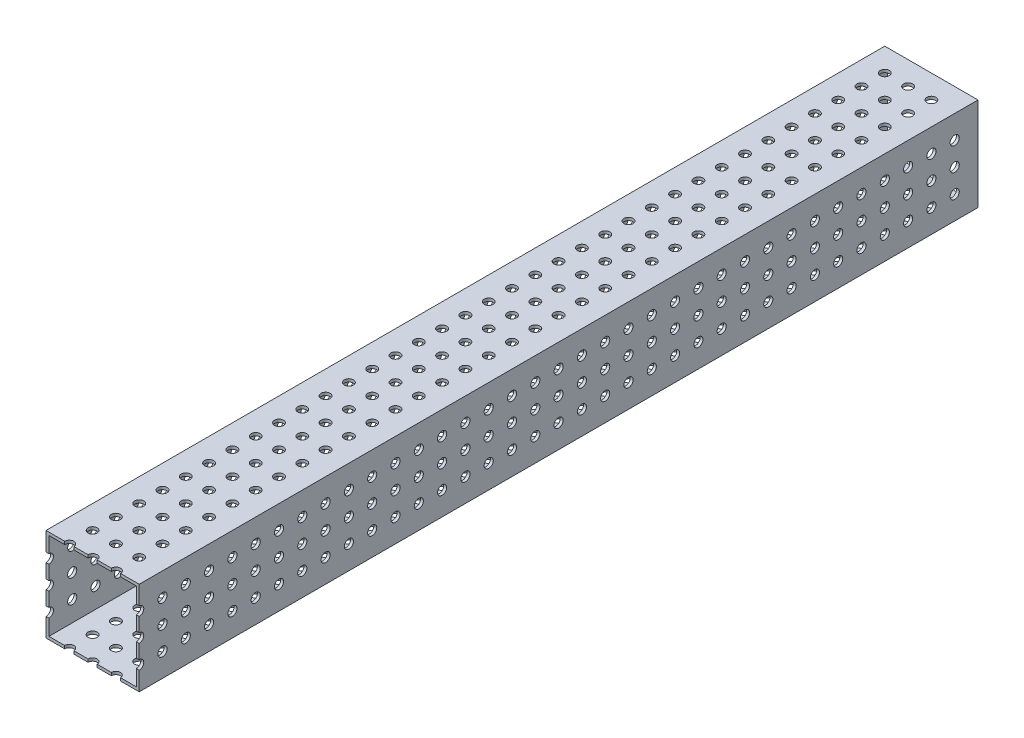
from build123d import *

# Parameters (mm, degrees)
SKETCH1_W           = 50.8
SKETCH1_H           = 50.8
SKETCH1_W_2         = 47.625
SKETCH1_H_2         = 47.625
BOSS_EXTRUDE1_DEPTH = 457.2
SKETCH2_R           = 2.4892
CUT_EXTRUDE1_DEPTH  = 51.8
SKETCH3_R           = 2.4892
CUT_EXTRUDE2_DEPTH  = 51.8


with BuildPart() as part:
    # Sketch1 → Boss-Extrude1 (new body)
    with BuildSketch(Plane.XY):
        with Locations((25.4, 25.4)):
            Rectangle(SKETCH1_W, SKETCH1_H)
        with Locations((25.4, 25.4)):
            Rectangle(SKETCH1_W_2, SKETCH1_H_2, mode=Mode.SUBTRACT)
    extrude(amount=BOSS_EXTRUDE1_DEPTH)

    # Sketch2 → Cut-Extrude1 (cut, through all)
    with BuildSketch(Plane(origin=(0, 50.8, 0), x_dir=(1, 0, 0), z_dir=(0, 1, 0))):
        with Locations((12.7, -12.7)):
            Circle(SKETCH2_R)
        with Locations((25.4, -12.7)):
            Circle(SKETCH2_R)
        with Locations((38.1, -12.7)):
            Circle(SKETCH2_R)
        with Locations((25.4, -25.4)):
            Circle(SKETCH2_R)
        with Locations((38.1, -25.4)):
            Circle(SKETCH2_R)
        with Locations((25.4, -38.1)):
            Circle(SKETCH2_R)
        with Locations((38.1, -38.1)):
            Circle(SKETCH2_R)
        with Locations((25.4, -50.8)):
            Circle(SKETCH2_R)
        with Locations((38.1, -50.8)):
            Circle(SKETCH2_R)
        with Locations((25.4, -63.5)):
            Circle(SKETCH2_R)
        with Locations((38.1, -63.5)):
            Circle(SKETCH2_R)
        with Locations((25.4, -76.2)):
            Circle(SKETCH2_R)
        with Locations((38.1, -76.2)):
            Circle(SKETCH2_R)
        with Locations((25.4, -88.9)):
            Circle(SKETCH2_R)
        with Locations((38.1, -88.9)):
            Circle(SKETCH2_R)
        with Locations((25.4, -101.6)):
            Circle(SKETCH2_R)
        with Locations((38.1, -101.6)):
            Circle(SKETCH2_R)
        with Locations((25.4, -114.3)):
            Circle(SKETCH2_R)
        with Locations((38.1, -114.3)):
            Circle(SKETCH2_R)
        with Locations((25.4, -127)):
            Circle(SKETCH2_R)
        with Locations((38.1, -127)):
            Circle(SKETCH2_R)
        with Locations((25.4, -139.7)):
            Circle(SKETCH2_R)
        with Locations((38.1, -139.7)):
            Circle(SKETCH2_R)
        with Locations((25.4, -152.4)):
            Circle(SKETCH2_R)
        with Locations((38.1, -152.4)):
            Circle(SKETCH2_R)
        with Locations((25.4, -165.1)):
            Circle(SKETCH2_R)
        with Locations((38.1, -165.1)):
            Circle(SKETCH2_R)
        with Locations((25.4, -177.8)):
            Circle(SKETCH2_R)
        with Locations((38.1, -177.8)):
            Circle(SKETCH2_R)
        with Locations((25.4, -190.5)):
            Circle(SKETCH2_R)
        with Locations((38.1, -190.5)):
            Circle(SKETCH2_R)
        with Locations((25.4, -203.2)):
            Circle(SKETCH2_R)
        with Locations((38.1, -203.2)):
            Circle(SKETCH2_R)
        with Locations((25.4, -215.9)):
            Circle(SKETCH2_R)
        with Locations((38.1, -215.9)):
            Circle(SKETCH2_R)
        with Locations((25.4, -228.6)):
            Circle(SKETCH2_R)
        with Locations((38.1, -228.6)):
            Circle(SKETCH2_R)
        with Locations((25.4, -241.3)):
            Circle(SKETCH2_R)
        with Locations((38.1, -241.3)):
            Circle(SKETCH2_R)
        with Locations((25.4, -254)):
            Circle(SKETCH2_R)
        with Locations((38.1, -254)):
            Circle(SKETCH2_R)
        with Locations((25.4, -266.7)):
            Circle(SKETCH2_R)
        with Locations((38.1, -266.7)):
            Circle(SKETCH2_R)
        with Locations((25.4, -279.4)):
            Circle(SKETCH2_R)
        with Locations((38.1, -279.4)):
            Circle(SKETCH2_R)
        with Locations((25.4, -292.1)):
            Circle(SKETCH2_R)
        with Locations((38.1, -292.1)):
            Circle(SKETCH2_R)
        with Locations((25.4, -304.8)):
            Circle(SKETCH2_R)
        with Locations((38.1, -304.8)):
            Circle(SKETCH2_R)
        with Locations((25.4, -317.5)):
            Circle(SKETCH2_R)
        with Locations((38.1, -317.5)):
            Circle(SKETCH2_R)
        with Locations((25.4, -330.2)):
            Circle(SKETCH2_R)
        with Locations((38.1, -330.2)):
            Circle(SKETCH2_R)
        with Locations((25.4, -342.9)):
            Circle(SKETCH2_R)
        with Locations((38.1, -342.9)):
            Circle(SKETCH2_R)
        with Locations((25.4, -355.6)):
            Circle(SKETCH2_R)
        with Locations((38.1, -355.6)):
            Circle(SKETCH2_R)
        with Locations((25.4, -368.3)):
            Circle(SKETCH2_R)
        with Locations((38.1, -368.3)):
            Circle(SKETCH2_R)
        with Locations((25.4, -381)):
            Circle(SKETCH2_R)
        with Locations((38.1, -381)):
            Circle(SKETCH2_R)
        with Locations((25.4, -393.7)):
            Circle(SKETCH2_R)
        with Locations((38.1, -393.7)):
            Circle(SKETCH2_R)
        with Locations((25.4, -406.4)):
            Circle(SKETCH2_R)
        with Locations((38.1, -406.4)):
            Circle(SKETCH2_R)
        with Locations((25.4, -419.1)):
            Circle(SKETCH2_R)
        with Locations((38.1, -419.1)):
            Circle(SKETCH2_R)
        with Locations((25.4, -431.8)):
            Circle(SKETCH2_R)
        with Locations((38.1, -431.8)):
            Circle(SKETCH2_R)
        with Locations((25.4, -444.5)):
            Circle(SKETCH2_R)
        with Locations((38.1, -444.5)):
            Circle(SKETCH2_R)
        with Locations((25.4, -457.2)):
            Circle(SKETCH2_R)
        with Locations((38.1, -457.2)):
            Circle(SKETCH2_R)
        with Locations((12.7, -25.4)):
            Circle(SKETCH2_R)
        with Locations((12.7, -38.1)):
            Circle(SKETCH2_R)
        with Locations((12.7, -50.8)):
            Circle(SKETCH2_R)
        with Locations((12.7, -63.5)):
            Circle(SKETCH2_R)
        with Locations((12.7, -76.2)):
            Circle(SKETCH2_R)
        with Locations((12.7, -88.9)):
            Circle(SKETCH2_R)
        with Locations((12.7, -101.6)):
            Circle(SKETCH2_R)
        with Locations((12.7, -114.3)):
            Circle(SKETCH2_R)
        with Locations((12.7, -127)):
            Circle(SKETCH2_R)
        with Locations((12.7, -139.7)):
            Circle(SKETCH2_R)
        with Locations((12.7, -152.4)):
            Circle(SKETCH2_R)
        with Locations((12.7, -165.1)):
            Circle(SKETCH2_R)
        with Locations((12.7, -177.8)):
            Circle(SKETCH2_R)
        with Locations((12.7, -190.5)):
            Circle(SKETCH2_R)
        with Locations((12.7, -203.2)):
            Circle(SKETCH2_R)
        with Locations((12.7, -215.9)):
            Circle(SKETCH2_R)
        with Locations((12.7, -228.6)):
            Circle(SKETCH2_R)
        with Locations((12.7, -241.3)):
            Circle(SKETCH2_R)
        with Locations((12.7, -254)):
            Circle(SKETCH2_R)
        with Locations((12.7, -266.7)):
            Circle(SKETCH2_R)
        with Locations((12.7, -279.4)):
            Circle(SKETCH2_R)
        with Locations((12.7, -292.1)):
            Circle(SKETCH2_R)
        with Locations((12.7, -304.8)):
            Circle(SKETCH2_R)
        with Locations((12.7, -317.5)):
            Circle(SKETCH2_R)
        with Locations((12.7, -330.2)):
            Circle(SKETCH2_R)
        with Locations((12.7, -342.9)):
            Circle(SKETCH2_R)
        with Locations((12.7, -355.6)):
            Circle(SKETCH2_R)
        with Locations((12.7, -368.3)):
            Circle(SKETCH2_R)
        with Locations((12.7, -381)):
            Circle(SKETCH2_R)
        with Locations((12.7, -393.7)):
            Circle(SKETCH2_R)
        with Locations((12.7, -406.4)):
            Circle(SKETCH2_R)
        with Locations((12.7, -419.1)):
            Circle(SKETCH2_R)
        with Locations((12.7, -431.8)):
            Circle(SKETCH2_R)
        with Locations((12.7, -444.5)):
            Circle(SKETCH2_R)
        with Locations((12.7, -457.2)):
            Circle(SKETCH2_R)
    extrude(amount=-CUT_EXTRUDE1_DEPTH, mode=Mode.SUBTRACT)

    # Sketch3 → Cut-Extrude2 (cut, through all)
    with BuildSketch(Plane.ZY):
        with Locations((12.7, 38.1)):
            Circle(SKETCH3_R)
        with Locations((25.4, 38.1)):
            Circle(SKETCH3_R)
        with Locations((38.1, 38.1)):
            Circle(SKETCH3_R)
        with Locations((50.8, 38.1)):
            Circle(SKETCH3_R)
        with Locations((63.5, 38.1)):
            Circle(SKETCH3_R)
        with Locations((76.2, 38.1)):
            Circle(SKETCH3_R)
        with Locations((88.9, 38.1)):
            Circle(SKETCH3_R)
        with Locations((101.6, 38.1)):
            Circle(SKETCH3_R)
        with Locations((114.3, 38.1)):
            Circle(SKETCH3_R)
        with Locations((127, 38.1)):
            Circle(SKETCH3_R)
        with Locations((139.7, 38.1)):
            Circle(SKETCH3_R)
        with Locations((152.4, 38.1)):
            Circle(SKETCH3_R)
        with Locations((165.1, 38.1)):
            Circle(SKETCH3_R)
        with Locations((177.8, 38.1)):
            Circle(SKETCH3_R)
        with Locations((190.5, 38.1)):
            Circle(SKETCH3_R)
        with Locations((203.2, 38.1)):
            Circle(SKETCH3_R)
        with Locations((215.9, 38.1)):
            Circle(SKETCH3_R)
        with Locations((228.6, 38.1)):
            Circle(SKETCH3_R)
        with Locations((241.3, 38.1)):
            Circle(SKETCH3_R)
        with Locations((254, 38.1)):
            Circle(SKETCH3_R)
        with Locations((266.7, 38.1)):
            Circle(SKETCH3_R)
        with Locations((279.4, 38.1)):
            Circle(SKETCH3_R)
        with Locations((292.1, 38.1)):
            Circle(SKETCH3_R)
        with Locations((304.8, 38.1)):
            Circle(SKETCH3_R)
        with Locations((317.5, 38.1)):
            Circle(SKETCH3_R)
        with Locations((330.2, 38.1)):
            Circle(SKETCH3_R)
        with Locations((342.9, 38.1)):
            Circle(SKETCH3_R)
        with Locations((355.6, 38.1)):
            Circle(SKETCH3_R)
        with Locations((368.3, 38.1)):
            Circle(SKETCH3_R)
        with Locations((381, 38.1)):
            Circle(SKETCH3_R)
        with Locations((393.7, 38.1)):
            Circle(SKETCH3_R)
        with Locations((406.4, 38.1)):
            Circle(SKETCH3_R)
        with Locations((419.1, 38.1)):
            Circle(SKETCH3_R)
        with Locations((431.8, 38.1)):
            Circle(SKETCH3_R)
        with Locations((444.5, 38.1)):
            Circle(SKETCH3_R)
        with Locations((457.2, 38.1)):
            Circle(SKETCH3_R)
        with Locations((25.4, 25.4)):
            Circle(SKETCH3_R)
        with Locations((38.1, 25.4)):
            Circle(SKETCH3_R)
        with Locations((50.8, 25.4)):
            Circle(SKETCH3_R)
        with Locations((63.5, 25.4)):
            Circle(SKETCH3_R)
        with Locations((76.2, 25.4)):
            Circle(SKETCH3_R)
        with Locations((88.9, 25.4)):
            Circle(SKETCH3_R)
        with Locations((101.6, 25.4)):
            Circle(SKETCH3_R)
        with Locations((114.3, 25.4)):
            Circle(SKETCH3_R)
        with Locations((127, 25.4)):
            Circle(SKETCH3_R)
        with Locations((139.7, 25.4)):
            Circle(SKETCH3_R)
        with Locations((152.4, 25.4)):
            Circle(SKETCH3_R)
        with Locations((165.1, 25.4)):
            Circle(SKETCH3_R)
        with Locations((177.8, 25.4)):
            Circle(SKETCH3_R)
        with Locations((190.5, 25.4)):
            Circle(SKETCH3_R)
        with Locations((203.2, 25.4)):
            Circle(SKETCH3_R)
        with Locations((215.9, 25.4)):
            Circle(SKETCH3_R)
        with Locations((228.6, 25.4)):
            Circle(SKETCH3_R)
        with Locations((241.3, 25.4)):
            Circle(SKETCH3_R)
        with Locations((254, 25.4)):
            Circle(SKETCH3_R)
        with Locations((266.7, 25.4)):
            Circle(SKETCH3_R)
        with Locations((279.4, 25.4)):
            Circle(SKETCH3_R)
        with Locations((292.1, 25.4)):
            Circle(SKETCH3_R)
        with Locations((304.8, 25.4)):
            Circle(SKETCH3_R)
        with Locations((317.5, 25.4)):
            Circle(SKETCH3_R)
        with Locations((330.2, 25.4)):
            Circle(SKETCH3_R)
        with Locations((342.9, 25.4)):
            Circle(SKETCH3_R)
        with Locations((355.6, 25.4)):
            Circle(SKETCH3_R)
        with Locations((368.3, 25.4)):
            Circle(SKETCH3_R)
        with Locations((381, 25.4)):
            Circle(SKETCH3_R)
        with Locations((393.7, 25.4)):
            Circle(SKETCH3_R)
        with Locations((406.4, 25.4)):
            Circle(SKETCH3_R)
        with Locations((419.1, 25.4)):
            Circle(SKETCH3_R)
        with Locations((431.8, 25.4)):
            Circle(SKETCH3_R)
        with Locations((444.5, 25.4)):
            Circle(SKETCH3_R)
        with Locations((457.2, 25.4)):
            Circle(SKETCH3_R)
        with Locations((25.4, 12.7)):
            Circle(SKETCH3_R)
        with Locations((38.1, 12.7)):
            Circle(SKETCH3_R)
        with Locations((50.8, 12.7)):
            Circle(SKETCH3_R)
        with Locations((63.5, 12.7)):
            Circle(SKETCH3_R)
        with Locations((76.2, 12.7)):
            Circle(SKETCH3_R)
        with Locations((88.9, 12.7)):
            Circle(SKETCH3_R)
        with Locations((101.6, 12.7)):
            Circle(SKETCH3_R)
        with Locations((114.3, 12.7)):
            Circle(SKETCH3_R)
        with Locations((127, 12.7)):
            Circle(SKETCH3_R)
        with Locations((139.7, 12.7)):
            Circle(SKETCH3_R)
        with Locations((152.4, 12.7)):
            Circle(SKETCH3_R)
        with Locations((165.1, 12.7)):
            Circle(SKETCH3_R)
        with Locations((177.8, 12.7)):
            Circle(SKETCH3_R)
        with Locations((190.5, 12.7)):
            Circle(SKETCH3_R)
        with Locations((203.2, 12.7)):
            Circle(SKETCH3_R)
        with Locations((215.9, 12.7)):
            Circle(SKETCH3_R)
        with Locations((228.6, 12.7)):
            Circle(SKETCH3_R)
        with Locations((241.3, 12.7)):
            Circle(SKETCH3_R)
        with Locations((254, 12.7)):
            Circle(SKETCH3_R)
        with Locations((266.7, 12.7)):
            Circle(SKETCH3_R)
        with Locations((279.4, 12.7)):
            Circle(SKETCH3_R)
        with Locations((292.1, 12.7)):
            Circle(SKETCH3_R)
        with Locations((304.8, 12.7)):
            Circle(SKETCH3_R)
        with Locations((317.5, 12.7)):
            Circle(SKETCH3_R)
        with Locations((330.2, 12.7)):
            Circle(SKETCH3_R)
        with Locations((342.9, 12.7)):
            Circle(SKETCH3_R)
        with Locations((355.6, 12.7)):
            Circle(SKETCH3_R)
        with Locations((368.3, 12.7)):
            Circle(SKETCH3_R)
        with Locations((381, 12.7)):
            Circle(SKETCH3_R)
        with Locations((393.7, 12.7)):
            Circle(SKETCH3_R)
        with Locations((406.4, 12.7)):
            Circle(SKETCH3_R)
        with Locations((419.1, 12.7)):
            Circle(SKETCH3_R)
        with Locations((431.8, 12.7)):
            Circle(SKETCH3_R)
        with Locations((444.5, 12.7)):
            Circle(SKETCH3_R)
        with Locations((457.2, 12.7)):
            Circle(SKETCH3_R)
        with Locations((12.7, 25.4)):
            Circle(SKETCH3_R)
        with Locations((12.7, 12.7)):
            Circle(SKETCH3_R)
    extrude(amount=-CUT_EXTRUDE2_DEPTH, mode=Mode.SUBTRACT)


solid = part.part
